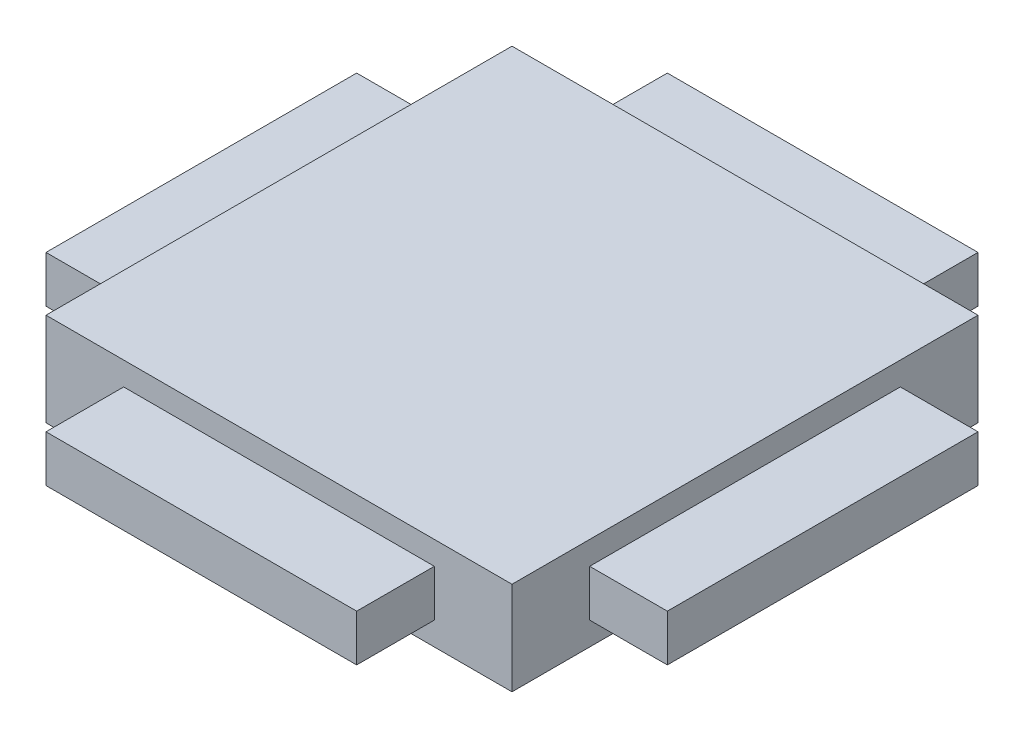
from build123d import *

# Parameters (mm, degrees)
SKETCH1_W                = 15
SKETCH1_H                = 15
BOSS_EXTRUDE2_DEPTH      = 3
SKETCH4_W                = 2.5
SKETCH4_H                = 10
SKETCH4_W_2              = 10
SKETCH4_H_2              = 2.5
BOSS_EXTRUDE3_DEPTH      = 0.75
BOSS_EXTRUDE3_DEPTH_BACK = 0.75


with BuildPart() as part:
    # Sketch1 → Boss-Extrude2 (new body)
    with BuildSketch(Plane(origin=(0, 0, 0), x_dir=(1, 0, 0), z_dir=(0, 1, 0))):
        Rectangle(SKETCH1_W, SKETCH1_H)
    extrude(amount=BOSS_EXTRUDE2_DEPTH)

    # Sketch4 → Boss-Extrude3 (add, two sides)
    with BuildSketch(Plane(origin=(0, 1.5, 0), x_dir=(1, 0, 0), z_dir=(0, 1, 0))) as boss_extrude3_sk:
        with Locations((-8.75, 0)):
            Rectangle(SKETCH4_W, SKETCH4_H)
        with Locations((0, -8.75)):
            Rectangle(SKETCH4_W_2, SKETCH4_H_2)
        with Locations((8.75, 0)):
            Rectangle(SKETCH4_W, SKETCH4_H)
        with Locations((0, 8.75)):
            Rectangle(SKETCH4_W_2, SKETCH4_H_2)
    extrude(amount=BOSS_EXTRUDE3_DEPTH)
    extrude(boss_extrude3_sk.sketch, amount=-BOSS_EXTRUDE3_DEPTH_BACK)


solid = part.part
